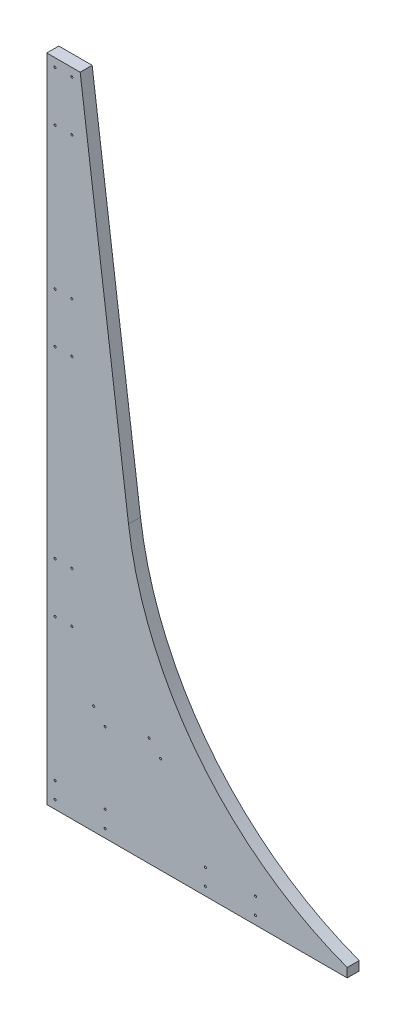
from build123d import *

# Parameters (mm, degrees)
BOSS_EXTRUDE1_DEPTH = 18.25625
SKETCH2_R           = 1.5875
CUT_EXTRUDE1_DEPTH  = 19.25625
SKETCH3_R           = 1.5875
CUT_EXTRUDE2_DEPTH  = 19.25625


with BuildPart() as part:
    # Sketch1 → Boss-Extrude1 (new body)
    with BuildSketch(Plane.XY):
        with BuildLine():
            Line((0, 990.6), (0, 0))
            Line((0, 0), (457.201, 0))
            Line((457.201, 0), (457.201, 13.862038208))
            ThreePointArc((457.201, 13.862038208), (232.767577124, 176.628269142), (124.367415652, 431.8))
            Line((124.367415652, 431.8), (50.8, 990.6))
            Line((50.8, 990.6), (0, 990.6))
        make_face()
    extrude(amount=BOSS_EXTRUDE1_DEPTH)

    # Sketch2 → Cut-Extrude1 (cut, through all)
    with BuildSketch(Plane.XY.offset(18.25625)):
        with Locations((12.7, 977.9)):
            Circle(SKETCH2_R)
        with Locations((38.1, 977.9)):
            Circle(SKETCH2_R)
        with Locations((12.7, 901.7)):
            Circle(SKETCH2_R)
        with Locations((38.1, 901.7)):
            Circle(SKETCH2_R)
        with Locations((12.7, 609.6)):
            Circle(SKETCH2_R)
        with Locations((38.1, 609.6)):
            Circle(SKETCH2_R)
        with Locations((12.7, 685.8)):
            Circle(SKETCH2_R)
        with Locations((38.1, 685.8)):
            Circle(SKETCH2_R)
        with Locations((12.7, 254)):
            Circle(SKETCH2_R)
        with Locations((38.1, 254)):
            Circle(SKETCH2_R)
        with Locations((12.7, 330.2)):
            Circle(SKETCH2_R)
        with Locations((38.1, 330.2)):
            Circle(SKETCH2_R)
        with Locations((12.7, 38.1)):
            Circle(SKETCH2_R)
        with Locations((12.7, 12.7)):
            Circle(SKETCH2_R)
        with Locations((88.9, 38.1)):
            Circle(SKETCH2_R)
        with Locations((88.9, 12.7)):
            Circle(SKETCH2_R)
        with Locations((241.3, 38.1)):
            Circle(SKETCH2_R)
        with Locations((317.5, 38.1)):
            Circle(SKETCH2_R)
        with Locations((241.3, 12.7)):
            Circle(SKETCH2_R)
        with Locations((317.5, 12.7)):
            Circle(SKETCH2_R)
    extrude(amount=-CUT_EXTRUDE1_DEPTH, mode=Mode.SUBTRACT)

    # Sketch3 → Cut-Extrude2 (cut, through all)
    with BuildSketch(Plane.XY.offset(18.25625)):
        with Locations((88.9, 147.112433493)):
            Circle(SKETCH3_R)
        with Locations((71.4248, 165.527433493)):
            Circle(SKETCH3_R)
        with Locations((155.8036, 165.527433493)):
            Circle(SKETCH3_R)
        with Locations((173.2788, 147.112433493)):
            Circle(SKETCH3_R)
    extrude(amount=-CUT_EXTRUDE2_DEPTH, mode=Mode.SUBTRACT)


solid = part.part
